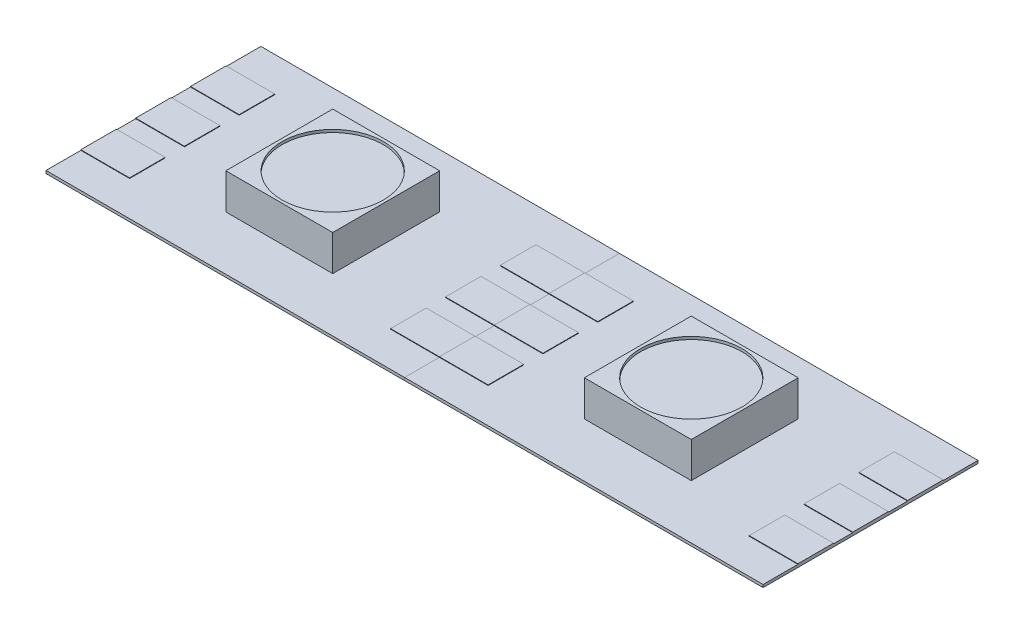
from build123d import *

# Parameters (mm, degrees)
SKETCH1_W           = 16.6116
SKETCH1_H           = 9.9568
BOSS_EXTRUDE1_DEPTH = 0.127
SKETCH3_W           = 4.953
SKETCH3_H           = 4.953
BOSS_EXTRUDE3_DEPTH = 1.651
SKETCH4_W           = 2.258810151
SKETCH4_H           = 1.651
BOSS_EXTRUDE4_DEPTH = 0.0254
SKETCH5_R           = 2.348345572
CUT_EXTRUDE1_DEPTH  = 0.127
LPATTERN1_COUNT     = 2
LPATTERN1_PITCH     = 16.6116


with BuildPart() as part:
    # Sketch1 → Boss-Extrude1 (new body)
    with BuildSketch(Plane(origin=(0, 0, 0), x_dir=(1, 0, 0), z_dir=(0, 1, 0))):
        Rectangle(SKETCH1_W, SKETCH1_H)
    extrude(amount=BOSS_EXTRUDE1_DEPTH)

    # Sketch3 → Boss-Extrude3 (add)
    with BuildSketch(Plane(origin=(0, 0.127, 0), x_dir=(1, 0, 0), z_dir=(0, 1, 0))):
        Rectangle(SKETCH3_W, SKETCH3_H)
    extrude(amount=BOSS_EXTRUDE3_DEPTH)

    # Sketch4 → Boss-Extrude4 (add)
    with BuildSketch(Plane(origin=(0, 0.127, 0), x_dir=(1, 0, 0), z_dir=(0, 1, 0))):
        with Locations((-7.176394925, 0)):
            Rectangle(SKETCH4_W, SKETCH4_H)
        with Locations((-7.176394925, 2.54)):
            Rectangle(SKETCH4_W, SKETCH4_H)
        with Locations((-7.176394925, -2.54)):
            Rectangle(SKETCH4_W, SKETCH4_H)
        with Locations((7.176394925, -2.54)):
            Rectangle(SKETCH4_W, SKETCH4_H)
        with Locations((7.176394925, 0)):
            Rectangle(SKETCH4_W, SKETCH4_H)
        with Locations((7.176394925, 2.54)):
            Rectangle(SKETCH4_W, SKETCH4_H)
    extrude(amount=BOSS_EXTRUDE4_DEPTH)

    # Sketch5 → Cut-Extrude1 (cut)
    with BuildSketch(Plane(origin=(0, 1.778, 0), x_dir=(1, 0, 0), z_dir=(0, 1, 0))):
        Circle(SKETCH5_R)
    extrude(amount=-CUT_EXTRUDE1_DEPTH, mode=Mode.SUBTRACT)


with BuildPart() as lpattern1_1:
    # LPattern1: pattern copy
    add(part.part.moved(Location(Vector(1, 0, 0) * (1 * LPATTERN1_PITCH))))


solid = Compound([part.part, lpattern1_1.part])
